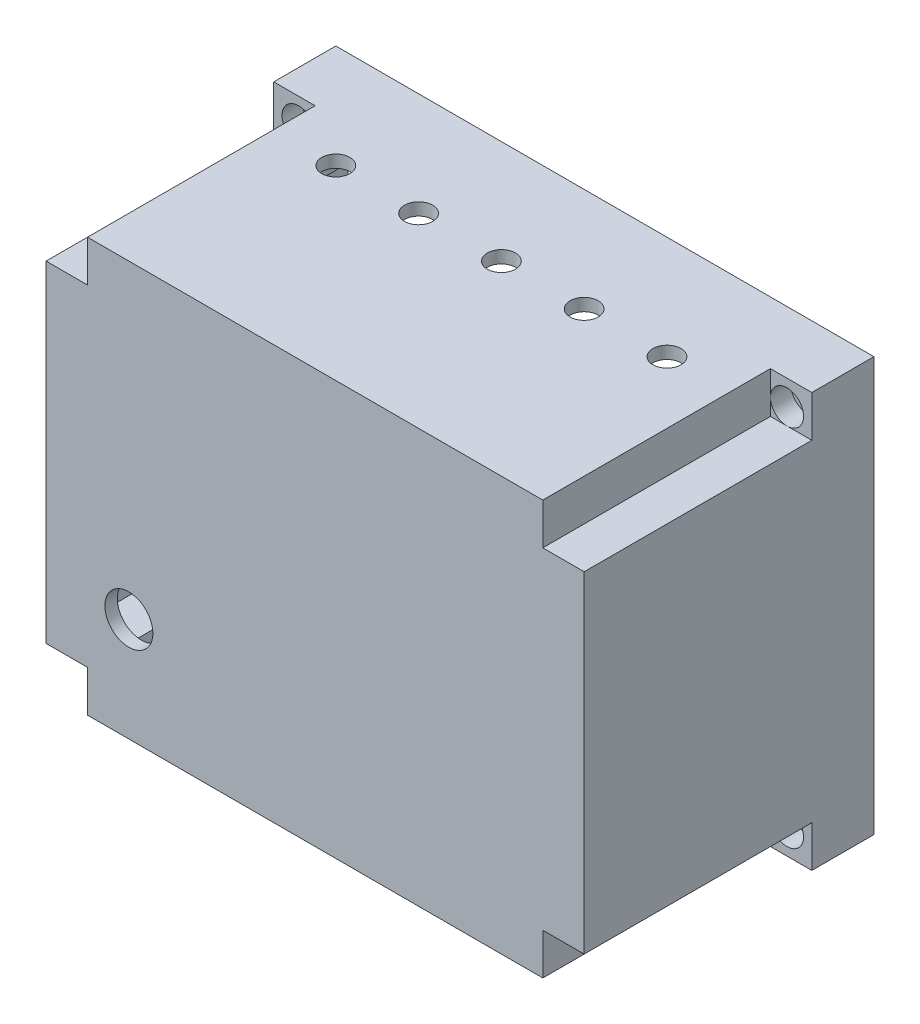
from build123d import *

# Parameters (mm, degrees)
SKETCH2_W           = 130
SKETCH2_H           = 70
BOSS_EXTRUDE1_DEPTH = 100
SKETCH3_W           = 104
SKETCH3_H           = 74
CUT_EXTRUDE1_DEPTH  = 67
SKETCH4_W           = 10
SKETCH4_H           = 10
CUT_EXTRUDE2_DEPTH  = 55
SKETCH5_W           = 104
SKETCH5_H           = 10
CUT_EXTRUDE3_DEPTH  = 67
SKETCH6_W           = 10
SKETCH6_H           = 74
CUT_EXTRUDE4_DEPTH  = 67
SKETCH9_R           = 1.75
CUT_EXTRUDE5_DEPTH  = 67
SKETCH10_R          = 4
CUT_EXTRUDE6_DEPTH  = 5
SKETCH12_R          = 4
CUT_EXTRUDE7_DEPTH  = 5
SKETCH13_R          = 4
CUT_EXTRUDE8_DEPTH  = 5
SKETCH14_R          = 4
CUT_EXTRUDE9_DEPTH  = 5
SKETCH15_W          = 3
SKETCH15_H          = 3
BOSS_EXTRUDE2_DEPTH = 5
SKETCH16_W          = 76
SKETCH16_H          = 3
BOSS_EXTRUDE3_DEPTH = 15
SKETCH17_W          = 3
SKETCH17_H          = 30
BOSS_EXTRUDE4_DEPTH = 15
SKETCH18_R          = 5.8
CUT_EXTRUDE10_DEPTH = 15
SKETCH19_R          = 3.4
CUT_EXTRUDE11_DEPTH = 15


with BuildPart() as part:
    # Sketch2 → Boss-Extrude1 (new body)
    with BuildSketch(Plane(origin=(0, 0, 0), x_dir=(1, 0, 0), z_dir=(0, 1, 0))):
        with Locations((65, 35)):
            Rectangle(SKETCH2_W, SKETCH2_H)
    extrude(amount=BOSS_EXTRUDE1_DEPTH)

    # Sketch3 → Cut-Extrude1 (cut)
    with BuildSketch(Plane(origin=(0, 0, -70), x_dir=(-1, 0, 0), z_dir=(0, 0, -1))):
        with Locations((-65, 50)):
            Rectangle(SKETCH3_W, SKETCH3_H)
    extrude(amount=-CUT_EXTRUDE1_DEPTH, mode=Mode.SUBTRACT)

    # Sketch4 → Cut-Extrude2 (cut)
    with BuildSketch(Plane.XY):
        with Locations((5, 95)):
            Rectangle(SKETCH4_W, SKETCH4_H)
        with Locations((125, 95)):
            Rectangle(SKETCH4_W, SKETCH4_H)
        with Locations((5, 5)):
            Rectangle(SKETCH4_W, SKETCH4_H)
        with Locations((125, 5)):
            Rectangle(SKETCH4_W, SKETCH4_H)
    extrude(amount=-CUT_EXTRUDE2_DEPTH, mode=Mode.SUBTRACT)

    # Sketch5 → Cut-Extrude3 (cut)
    with BuildSketch(Plane(origin=(0, 0, -70), x_dir=(-1, 0, 0), z_dir=(0, 0, -1))):
        with Locations((-65, 92)):
            Rectangle(SKETCH5_W, SKETCH5_H)
        with Locations((-65, 8)):
            Rectangle(SKETCH5_W, SKETCH5_H)
    extrude(amount=-CUT_EXTRUDE3_DEPTH, mode=Mode.SUBTRACT)

    # Sketch6 → Cut-Extrude4 (cut)
    with BuildSketch(Plane(origin=(0, 0, -70), x_dir=(-1, 0, 0), z_dir=(0, 0, -1))):
        with Locations((-122, 50)):
            Rectangle(SKETCH6_W, SKETCH6_H)
        with Locations((-8, 50)):
            Rectangle(SKETCH6_W, SKETCH6_H)
    extrude(amount=-CUT_EXTRUDE4_DEPTH, mode=Mode.SUBTRACT)

    # Sketch9 → Cut-Extrude5 (cut)
    with BuildSketch(Plane(origin=(0, 0, -70), x_dir=(-1, 0, 0), z_dir=(0, 0, -1))):
        with Locations((-124, 94)):
            Circle(SKETCH9_R)
        with Locations((-124, 6)):
            Circle(SKETCH9_R)
        with Locations((-6, 94)):
            Circle(SKETCH9_R)
        with Locations((-6, 6)):
            Circle(SKETCH9_R)
    extrude(amount=-CUT_EXTRUDE5_DEPTH, mode=Mode.SUBTRACT)

    # Sketch10 → Cut-Extrude6 (cut)
    with BuildSketch(Plane.XY.offset(-55)):
        with Locations((124, 94)):
            Circle(SKETCH10_R)
    extrude(amount=-CUT_EXTRUDE6_DEPTH, mode=Mode.SUBTRACT)

    # Sketch12 → Cut-Extrude7 (cut)
    with BuildSketch(Plane.XY.offset(-55)):
        with Locations((124, 6)):
            Circle(SKETCH12_R)
    extrude(amount=-CUT_EXTRUDE7_DEPTH, mode=Mode.SUBTRACT)

    # Sketch13 → Cut-Extrude8 (cut)
    with BuildSketch(Plane.XY.offset(-55)):
        with Locations((6, 6)):
            Circle(SKETCH13_R)
    extrude(amount=-CUT_EXTRUDE8_DEPTH, mode=Mode.SUBTRACT)

    # Sketch14 → Cut-Extrude9 (cut)
    with BuildSketch(Plane.XY.offset(-55)):
        with Locations((6, 94)):
            Circle(SKETCH14_R)
    extrude(amount=-CUT_EXTRUDE9_DEPTH, mode=Mode.SUBTRACT)

    # Sketch15 → Boss-Extrude2 (add)
    with BuildSketch(Plane(origin=(0, 0, -70), x_dir=(-1, 0, 0), z_dir=(0, 0, -1))):
        with Locations((-118.5, 88.5)):
            Rectangle(SKETCH15_W, SKETCH15_H)
        with Locations((-118.5, 11.5)):
            Rectangle(SKETCH15_W, SKETCH15_H)
        with Locations((-11.5, 11.5)):
            Rectangle(SKETCH15_W, SKETCH15_H)
        with Locations((-11.5, 88.5)):
            Rectangle(SKETCH15_W, SKETCH15_H)
    extrude(amount=BOSS_EXTRUDE2_DEPTH)

    # Sketch16 → Boss-Extrude3 (add)
    with BuildSketch(Plane(origin=(0, 3, 0), x_dir=(1, 0, 0), z_dir=(0, 1, 0))):
        with Locations((79, 68.5)):
            Rectangle(SKETCH16_W, SKETCH16_H)
    extrude(amount=BOSS_EXTRUDE3_DEPTH)

    # Sketch17 → Boss-Extrude4 (add)
    with BuildSketch(Plane(origin=(0, 0, -3), x_dir=(-1, 0, 0), z_dir=(0, 0, -1))):
        with Locations((-99.5, 33)):
            Rectangle(SKETCH17_W, SKETCH17_H)
        with Locations((-36.5, 33)):
            Rectangle(SKETCH17_W, SKETCH17_H)
    extrude(amount=BOSS_EXTRUDE4_DEPTH)

    # Sketch18 → Cut-Extrude10 (cut)
    with BuildSketch(Plane(origin=(0, 0, -3), x_dir=(-1, 0, 0), z_dir=(0, 0, -1))):
        with Locations((-20, 25)):
            Circle(SKETCH18_R)
    extrude(amount=-CUT_EXTRUDE10_DEPTH, mode=Mode.SUBTRACT)

    # Sketch19 → Cut-Extrude11 (cut)
    with BuildSketch(Plane(origin=(0, 100, 0), x_dir=(1, 0, 0), z_dir=(0, 1, 0))):
        with Locations((25, 45)):
            Circle(SKETCH19_R)
        with Locations((45, 45)):
            Circle(SKETCH19_R)
        with Locations((65, 45)):
            Circle(SKETCH19_R)
        with Locations((85, 45)):
            Circle(SKETCH19_R)
        with Locations((105, 45)):
            Circle(SKETCH19_R)
    extrude(amount=-CUT_EXTRUDE11_DEPTH, mode=Mode.SUBTRACT)


solid = part.part
